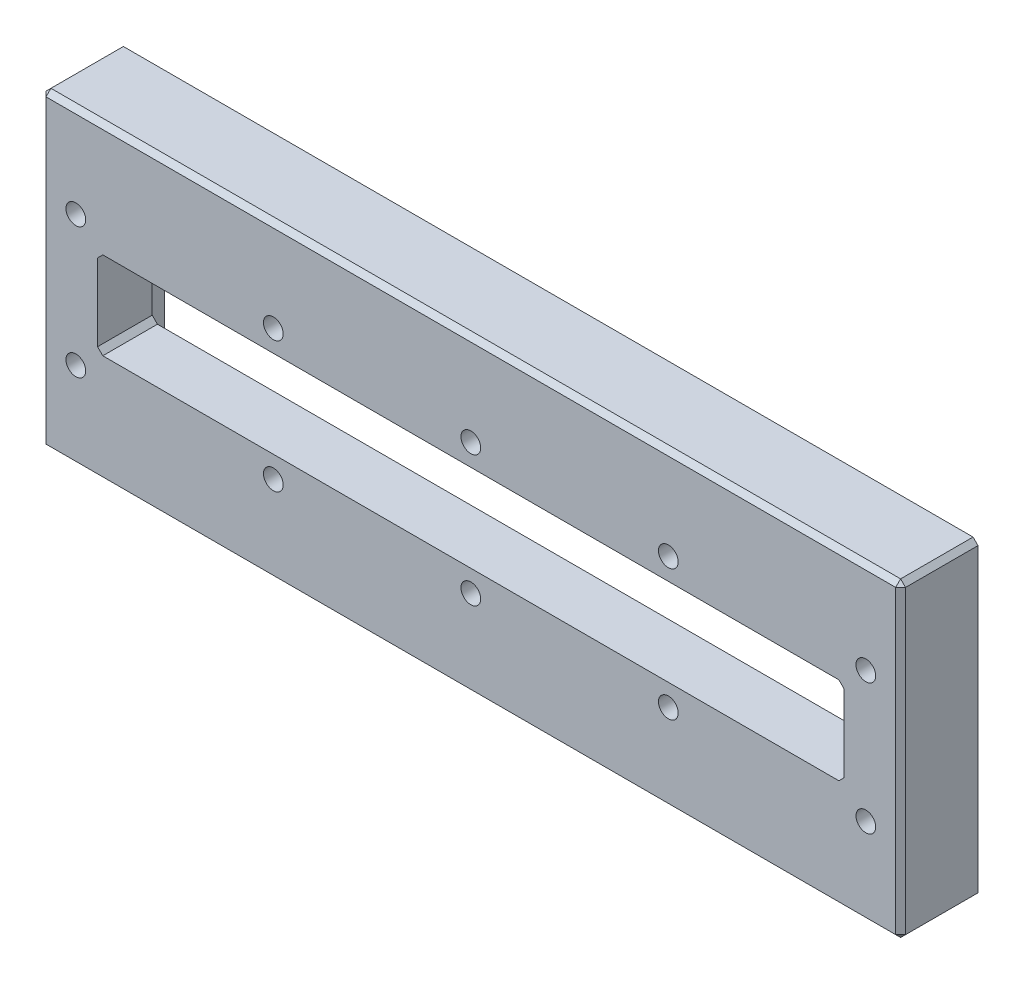
from build123d import *

# Parameters (mm, degrees)
SKETCH1_W           = 174.09
SKETCH1_H           = 62.91
SKETCH1_W_2         = 164.29
SKETCH1_H_2         = 53.11
BOSS_EXTRUDE1_DEPTH = 1.6
SKETCH2_W           = 174.09
SKETCH2_H           = 62.91
SKETCH2_W_2         = 152.29
SKETCH2_H_2         = 39.11
BOSS_EXTRUDE2_DEPTH = 3
SKETCH3_W           = 174.09
SKETCH3_H           = 62.91
BOSS_EXTRUDE3_DEPTH = 11.07
SKETCH4_R           = 0.8
CUT_EXTRUDE1_DEPTH  = 10
SKETCH5_R           = 0.75
CUT_EXTRUDE2_DEPTH  = 1.6
FILLET1_R           = 1
SKETCH6_R           = 2
CUT_EXTRUDE3_DEPTH  = 10
CHAMFER1_SIZE       = 1


with BuildPart() as part:
    # Sketch1 → Boss-Extrude1 (new body)
    with BuildSketch(Plane.XY.offset(1006.65)):
        with Locations((-13.164391743, 25.723524096)):
            Rectangle(SKETCH1_W, SKETCH1_H)
        with Locations((-13.164391743, 25.723524096)):
            Rectangle(SKETCH1_W_2, SKETCH1_H_2, mode=Mode.SUBTRACT)
    extrude(amount=-BOSS_EXTRUDE1_DEPTH)

    # Sketch2 → Boss-Extrude2 (add)
    with BuildSketch(Plane.XY.offset(1006.65)):
        with Locations((-13.164391743, 25.723524096)):
            Rectangle(SKETCH2_W, SKETCH2_H)
        with Locations((-13.164391743, 25.723524096)):
            Rectangle(SKETCH2_W_2, SKETCH2_H_2, mode=Mode.SUBTRACT)
    extrude(amount=BOSS_EXTRUDE2_DEPTH)

    # Sketch3 → Boss-Extrude3 (add)
    with BuildSketch(Plane.XY.offset(1009.65)):
        with Locations((-13.164391743, 25.723524096)):
            Rectangle(SKETCH3_W, SKETCH3_H)
        Polygon((61.377029613, 34.213523596), (-87.705813099, 34.213523596), (-88.764391743, 33.154944952), (-88.764391743, 24.613523596), (-88.764391743, 17.57210224), (-87.705813099, 16.513523596), (61.377029613, 16.513523596), (62.435608257, 17.57210224), (62.435608257, 24.613523596), (62.435608257, 33.154944952), align=None, mode=Mode.SUBTRACT)
    extrude(amount=BOSS_EXTRUDE3_DEPTH)

    # Sketch4 → Cut-Extrude1 (cut)
    with BuildSketch(Plane(origin=(0, 0, 1006.65), x_dir=(-1, 0, 0), z_dir=(0, 0, -1))):
        with Locations((-46.835608257, 50.678524096)):
            Circle(SKETCH4_R)
        with Locations((-16.835608257, 50.678524096)):
            Circle(SKETCH4_R)
        with Locations((13.164391743, 50.678524096)):
            Circle(SKETCH4_R)
        with Locations((43.164391743, 50.678524096)):
            Circle(SKETCH4_R)
        with Locations((73.164391743, 50.678524096)):
            Circle(SKETCH4_R)
        with Locations((73.164391743, 0.768524096)):
            Circle(SKETCH4_R)
        with Locations((43.164391743, 0.768524096)):
            Circle(SKETCH4_R)
        with Locations((13.164391743, 0.768524096)):
            Circle(SKETCH4_R)
        with Locations((-16.835608257, 0.768524096)):
            Circle(SKETCH4_R)
        with Locations((-46.835608257, 0.768524096)):
            Circle(SKETCH4_R)
    extrude(amount=-CUT_EXTRUDE1_DEPTH, mode=Mode.SUBTRACT)

    # Sketch5 → Cut-Extrude2 (cut)
    with BuildSketch(Plane(origin=(0, 0, 1005.05), x_dir=(-1, 0, 0), z_dir=(0, 0, -1))):
        with Locations((95.309391743, 52.278524096)):
            Circle(SKETCH5_R)
        with Locations((95.309391743, -0.831475904)):
            Circle(SKETCH5_R)
        with Locations((-68.980608257, -0.831475904)):
            Circle(SKETCH5_R)
        with Locations((-68.980608257, 52.278524096)):
            Circle(SKETCH5_R)
    extrude(amount=-CUT_EXTRUDE2_DEPTH, mode=Mode.SUBTRACT)

    # Fillet1
    fillet1_edges = [part.edges().sort_by_distance(p)[0] for p in [
        (68.980608257, 51.528524096, 1005.85),
        (68.230608257, 52.278524096, 1005.85),
        (68.230608257, -0.831475904, 1005.85),
        (68.980608257, -0.081475904, 1005.85),
        (-95.309391743, -0.081475904, 1005.85),
        (-94.559391743, -0.831475904, 1005.85),
        (-95.309391743, 51.528524096, 1005.85),
        (-94.559391743, 52.278524096, 1005.85),
    ]]
    fillet(fillet1_edges, radius=FILLET1_R)

    # Sketch6 → Cut-Extrude3 (cut)
    with BuildSketch(Plane.XY.offset(1020.72)):
        with Locations((-93.164391743, 38.613523596)):
            Circle(SKETCH6_R)
        with Locations((-53.164391743, 38.613523596)):
            Circle(SKETCH6_R)
        with Locations((-13.164391743, 38.613523596)):
            Circle(SKETCH6_R)
        with Locations((26.835608257, 38.613523596)):
            Circle(SKETCH6_R)
        with Locations((66.835608257, 38.613523596)):
            Circle(SKETCH6_R)
        with Locations((66.835608257, 12.113523596)):
            Circle(SKETCH6_R)
        with Locations((26.835608257, 12.113523596)):
            Circle(SKETCH6_R)
        with Locations((-13.164391743, 12.113523596)):
            Circle(SKETCH6_R)
        with Locations((-53.164391743, 12.113523596)):
            Circle(SKETCH6_R)
        with Locations((-93.164391743, 12.113523596)):
            Circle(SKETCH6_R)
    extrude(amount=-CUT_EXTRUDE3_DEPTH, mode=Mode.SUBTRACT)

    # Chamfer1
    chamfer1_edges = [part.edges().sort_by_distance(p)[0] for p in [
        (73.880608257, 57.178524096, 1012.885),
        (73.880608257, -5.731475904, 1012.885),
        (-100.209391743, -5.731475904, 1012.885),
        (-100.209391743, 57.178524096, 1012.885),
        (-13.164391743, 57.178524096, 1020.72),
        (-100.209391743, 25.723524096, 1020.72),
        (-13.164391743, -5.731475904, 1020.72),
        (73.880608257, 25.723524096, 1020.72),
        (-100.209391743, 25.723524096, 1005.05),
    ]]
    chamfer(chamfer1_edges, length=CHAMFER1_SIZE)


solid = part.part
